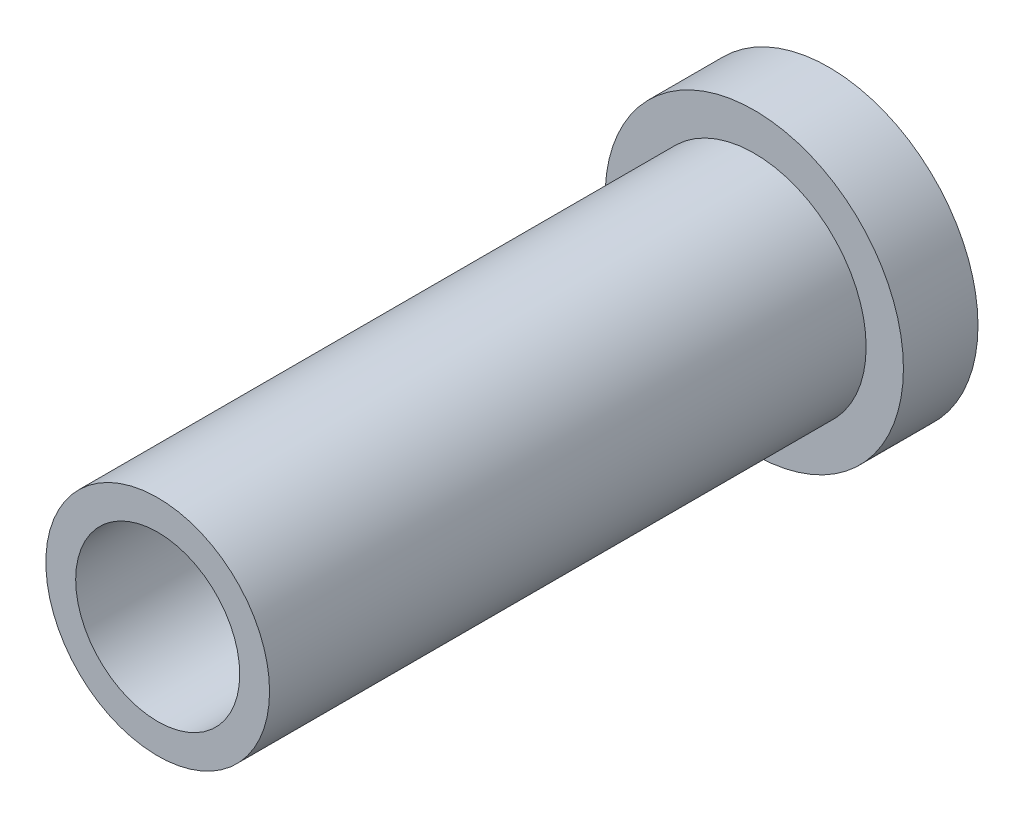
from build123d import *

# Parameters (mm, degrees)
SKETCH1_R           = 10
BOSS_EXTRUDE1_DEPTH = 5
SKETCH2_R           = 7.5
BOSS_EXTRUDE2_DEPTH = 40
SKETCH4_R           = 5.5
CUT_EXTRUDE1_DEPTH  = 45


with BuildPart() as part:
    # Sketch1 → Boss-Extrude1 (new body)
    with BuildSketch(Plane.XY):
        Circle(SKETCH1_R)
    extrude(amount=BOSS_EXTRUDE1_DEPTH)

    # Sketch2 → Boss-Extrude2 (add)
    with BuildSketch(Plane.XY.offset(5)):
        Circle(SKETCH2_R)
    extrude(amount=BOSS_EXTRUDE2_DEPTH)

    # Sketch4 → Cut-Extrude1 (cut)
    with BuildSketch(Plane(origin=(0, 0, 0), x_dir=(-1, 0, 0), z_dir=(0, 0, -1))):
        Circle(SKETCH4_R)
    extrude(amount=-CUT_EXTRUDE1_DEPTH, mode=Mode.SUBTRACT)


solid = part.part
